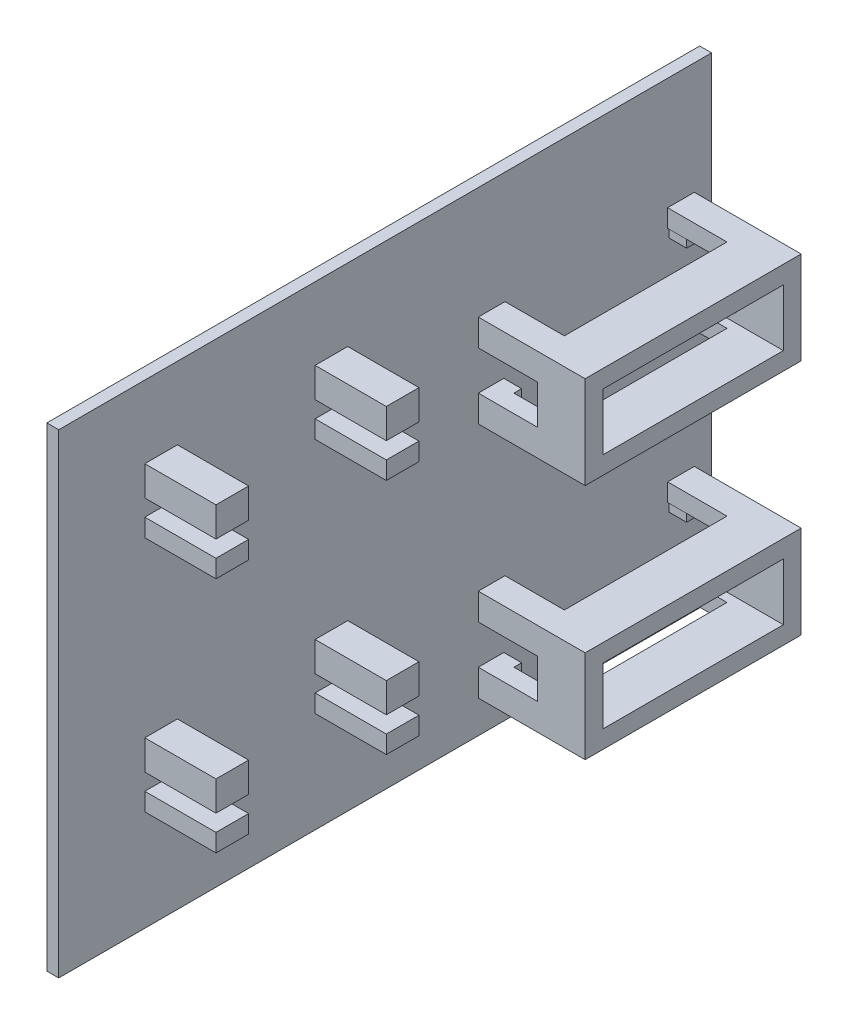
from build123d import *

# Parameters (mm, degrees)
SKETCH_1_W             = 140
SKETCH_1_H             = 80
EXTRUDE_1_DEPTH        = 2
SKETCH_2_W             = 5.5
SKETCH_2_H             = 5
SKETCH_2_H_2           = 3
EXTRUDE_2_DEPTH        = 12
SKETCH_3_W             = 30
SKETCH_3_H             = 80
CUT_EXTRUDE_1_DEPTH    = 3
SKETCH_4_W             = 36.4
SKETCH_4_H             = 15.6
SKETCH_4_W_2           = 30.4
SKETCH_4_H_2           = 9.6
EXTRUDE_3_DEPTH        = 18
SKETCH_5_W             = 10
SKETCH_5_H             = 27.4
CUT_EXTRUDE_2_DEPTH    = 20
SKETCH_6_W             = 1.3
SKETCH_6_H             = 9.6
EXTRUDE_4_DEPTH        = 3
SKETCH_8_W             = 10
SKETCH_8_H             = 6.6
CUT_EXTRUDE_3_DEPTH    = 40
PATTERN_LINEAR_1_COUNT = 2
PATTERN_LINEAR_1_PITCH = 40


with BuildPart() as part:
    # 草图1 → 凸台-拉伸1 (new body)
    with BuildSketch(Plane(origin=(0, 0, 0), x_dir=(0, 0, -1), z_dir=(1, 0, 0))):
        Rectangle(SKETCH_1_W, SKETCH_1_H)
    extrude(amount=EXTRUDE_1_DEPTH)

    # 草图2 → 凸台-拉伸2 (add)
    with BuildSketch(Plane(origin=(2, 0, 0), x_dir=(0, 0, -1), z_dir=(1, 0, 0))):
        with Locations((-24.05, -14.7)):
            Rectangle(SKETCH_2_W, SKETCH_2_H)
        with Locations((-52.75, -14.7)):
            Rectangle(SKETCH_2_W, SKETCH_2_H)
        with Locations((-24.05, -21.5)):
            Rectangle(SKETCH_2_W, SKETCH_2_H_2)
        with Locations((-52.75, 18.5)):
            Rectangle(SKETCH_2_W, SKETCH_2_H_2)
        with Locations((-24.05, 25.3)):
            Rectangle(SKETCH_2_W, SKETCH_2_H)
        with Locations((-52.75, -21.5)):
            Rectangle(SKETCH_2_W, SKETCH_2_H_2)
        with Locations((-24.05, 18.5)):
            Rectangle(SKETCH_2_W, SKETCH_2_H_2)
        with Locations((-52.75, 25.3)):
            Rectangle(SKETCH_2_W, SKETCH_2_H)
    extrude(amount=EXTRUDE_2_DEPTH)

    # 草图3 → 切除-拉伸1 (cut)
    with BuildSketch(Plane(origin=(2, 0, 0), x_dir=(0, 0, -1), z_dir=(1, 0, 0))):
        with Locations((55, 0)):
            Rectangle(SKETCH_3_W, SKETCH_3_H)
    extrude(amount=-CUT_EXTRUDE_1_DEPTH, mode=Mode.SUBTRACT)

    # 草图4 → 凸台-拉伸3 (add)
    with BuildSketch(Plane(origin=(2, 0, 0), x_dir=(0, 0, -1), z_dir=(1, 0, 0))):
        with Locations((18.9, -26.7)):
            Rectangle(SKETCH_4_W, SKETCH_4_H)
        with Locations((18.9, -26.7)):
            Rectangle(SKETCH_4_W_2, SKETCH_4_H_2, mode=Mode.SUBTRACT)
    extrude_3 = extrude(amount=EXTRUDE_3_DEPTH)

    # 草图5 → 切除-拉伸2 (cut)
    with BuildSketch(Plane.XZ.offset(34.5)):
        with Locations((7, -18.9)):
            Rectangle(SKETCH_5_W, SKETCH_5_H)
    cut_extrude_2 = extrude(amount=-CUT_EXTRUDE_2_DEPTH, mode=Mode.SUBTRACT)

    # 草图6 → 凸台-拉伸4 (add)
    with BuildSketch(Plane(origin=(2, 0, 0), x_dir=(0, 0, -1), z_dir=(1, 0, 0))):
        with Locations((4.35, -26.7)):
            Rectangle(SKETCH_6_W, SKETCH_6_H)
        with Locations((33.45, -26.7)):
            Rectangle(SKETCH_6_W, SKETCH_6_H)
    extrude_4 = extrude(amount=EXTRUDE_4_DEPTH)

    # 草图8 → 切除-拉伸3 (cut)
    with BuildSketch(Plane(origin=(0, 0, -37.1), x_dir=(-1, 0, 0), z_dir=(0, 0, -1))):
        with Locations((-7, -26.7)):
            Rectangle(SKETCH_8_W, SKETCH_8_H)
    cut_extrude_3 = extrude(amount=-CUT_EXTRUDE_3_DEPTH, mode=Mode.SUBTRACT)

    # 阵列(线性)1: 凸台-拉伸3, 切除-拉伸2, 凸台-拉伸4, 切除-拉伸3 ×2
    with Locations(*[(0, i * PATTERN_LINEAR_1_PITCH, 0) for i in range(1, PATTERN_LINEAR_1_COUNT)]):
        add(extrude_3)
        add(cut_extrude_2, mode=Mode.SUBTRACT)
        add(extrude_4)
        add(cut_extrude_3, mode=Mode.SUBTRACT)


solid = part.part
